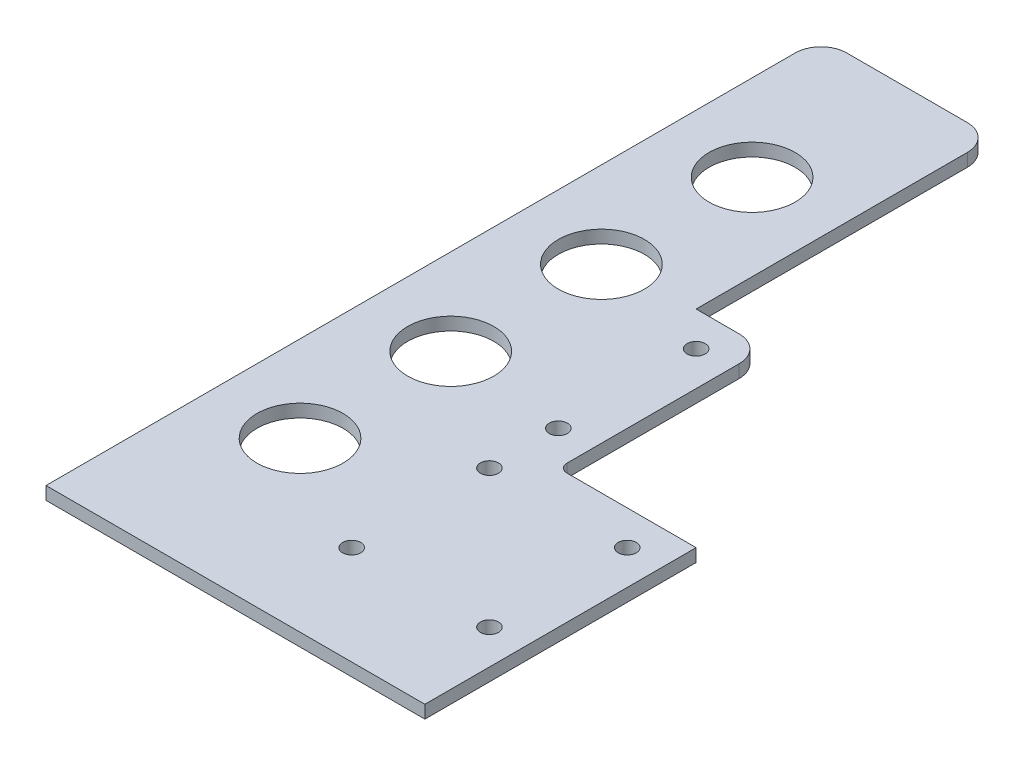
from build123d import *

# Parameters (mm, degrees)
SKETCH1_R               = 2.1
SKETCH1_R_2             = 10
BOSS_EXTRUDE1_DEPTH     = 3
SKETCH2_W               = 88
SKETCH2_H               = 4
CUT_EXTRUDE1_DEPTH      = 1
CUT_EXTRUDE1_DEPTH_BACK = 4


with BuildPart() as part:
    # Sketch1 → Boss-Extrude1 (new body)
    with BuildSketch(Plane(origin=(0, 0, 0), x_dir=(1, 0, 0), z_dir=(0, 1, 0))):
        with BuildLine():
            Line((-8, 26), (-8, 66))
            ThreePointArc((-8, 66), (-9.757359313, 70.242640687), (-14, 72))
            Line((-14, 72), (-24, 72))
            Line((-24, 72), (-24, 135))
            ThreePointArc((-24, 135), (-25.757359313, 139.242640687), (-30, 141))
            Line((-30, 141), (-58, 141))
            ThreePointArc((-58, 141), (-62.242640687, 139.242640687), (-64, 135))
            Line((-64, 135), (-64, -43))
            Line((-64, -43), (-24, -43))
            Line((-24, -43), (24, -43))
            Line((24, -43), (24, 24))
            Line((24, 24), (-6, 24))
            ThreePointArc((-6, 24), (-7.414213562, 24.585786438), (-8, 26))
        make_face()
        with Locations((16, 16)):
            Circle(SKETCH1_R, mode=Mode.SUBTRACT)
        with Locations((16, -16)):
            Circle(SKETCH1_R, mode=Mode.SUBTRACT)
        with Locations((-16, -16)):
            Circle(SKETCH1_R, mode=Mode.SUBTRACT)
        with Locations((-16, 16)):
            Circle(SKETCH1_R, mode=Mode.SUBTRACT)
        with Locations((-16, 32)):
            Circle(SKETCH1_R, mode=Mode.SUBTRACT)
        with Locations((-16, 64)):
            Circle(SKETCH1_R, mode=Mode.SUBTRACT)
        with Locations((-44, 0)):
            Circle(SKETCH1_R_2, mode=Mode.SUBTRACT)
        with Locations((-44, 35)):
            Circle(SKETCH1_R_2, mode=Mode.SUBTRACT)
        with Locations((-44, 70)):
            Circle(SKETCH1_R_2, mode=Mode.SUBTRACT)
        with Locations((-44, 105)):
            Circle(SKETCH1_R_2, mode=Mode.SUBTRACT)
    extrude(amount=BOSS_EXTRUDE1_DEPTH)

    # Sketch2 → Cut-Extrude1 (cut, two sides)
    with BuildSketch(Plane(origin=(0, 3, 0), x_dir=(1, 0, 0), z_dir=(0, 1, 0))) as cut_extrude1_sk:
        with Locations((-20, -41)):
            Rectangle(SKETCH2_W, SKETCH2_H)
    extrude(amount=CUT_EXTRUDE1_DEPTH, mode=Mode.SUBTRACT)
    extrude(cut_extrude1_sk.sketch, amount=-CUT_EXTRUDE1_DEPTH_BACK, mode=Mode.SUBTRACT)


solid = part.part
